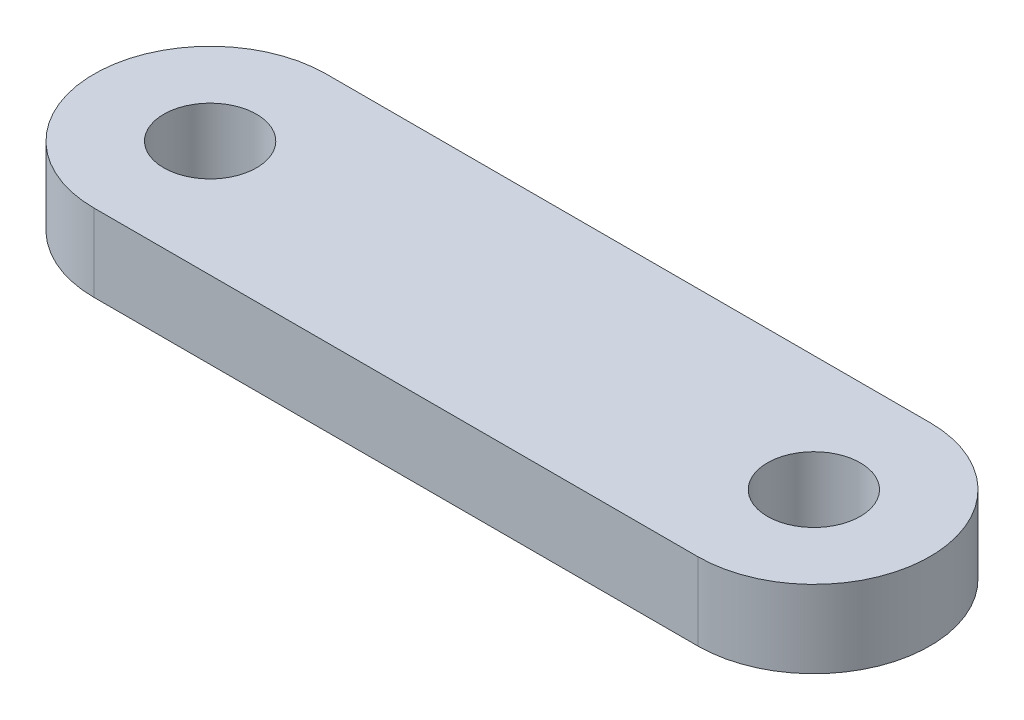
from build123d import *

# Parameters (mm, degrees)
SKETCH1_R           = 3
BOSS_EXTRUDE1_DEPTH = 5


with BuildPart() as part:
    # Sketch1 → Boss-Extrude1 (new body)
    with BuildSketch(Plane(origin=(0, 0, 0), x_dir=(1, 0, 0), z_dir=(0, 1, 0))):
        with BuildLine():
            Line((0, 7.5), (39, 7.5))
            ThreePointArc((39, 7.5), (46.5, 0), (39, -7.5))
            Line((39, -7.5), (0, -7.5))
            ThreePointArc((0, -7.5), (-7.5, 0), (0, 7.5))
        make_face()
        with Locations((39, 0)):
            Circle(SKETCH1_R, mode=Mode.SUBTRACT)
        Circle(SKETCH1_R, mode=Mode.SUBTRACT)
    extrude(amount=BOSS_EXTRUDE1_DEPTH)


solid = part.part
